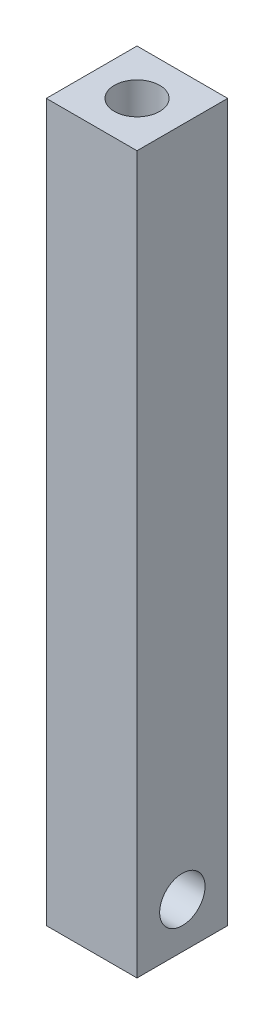
from build123d import *

# Parameters (mm, degrees)
SKETCH2_W           = 10
SKETCH2_H           = 79
SKETCH2_R           = 2.5
BOSS_EXTRUDE1_DEPTH = 10
SKETCH3_R           = 2.5
CUT_EXTRUDE1_DEPTH  = 5


with BuildPart() as part:
    # Sketch2 → Boss-Extrude1 (new body)
    with BuildSketch(Plane(origin=(0, 0, 0), x_dir=(0, 0, -1), z_dir=(1, 0, 0))):
        Rectangle(SKETCH2_W, SKETCH2_H)
        with Locations((0, -34.5)):
            Circle(SKETCH2_R, mode=Mode.SUBTRACT)
    extrude(amount=BOSS_EXTRUDE1_DEPTH)

    # Sketch3 → Cut-Extrude1 (cut)
    with BuildSketch(Plane(origin=(0, 39.5, 0), x_dir=(1, 0, 0), z_dir=(0, 1, 0))):
        with Locations((5, 0)):
            Circle(SKETCH3_R)
    extrude(amount=-CUT_EXTRUDE1_DEPTH, mode=Mode.SUBTRACT)


solid = part.part
